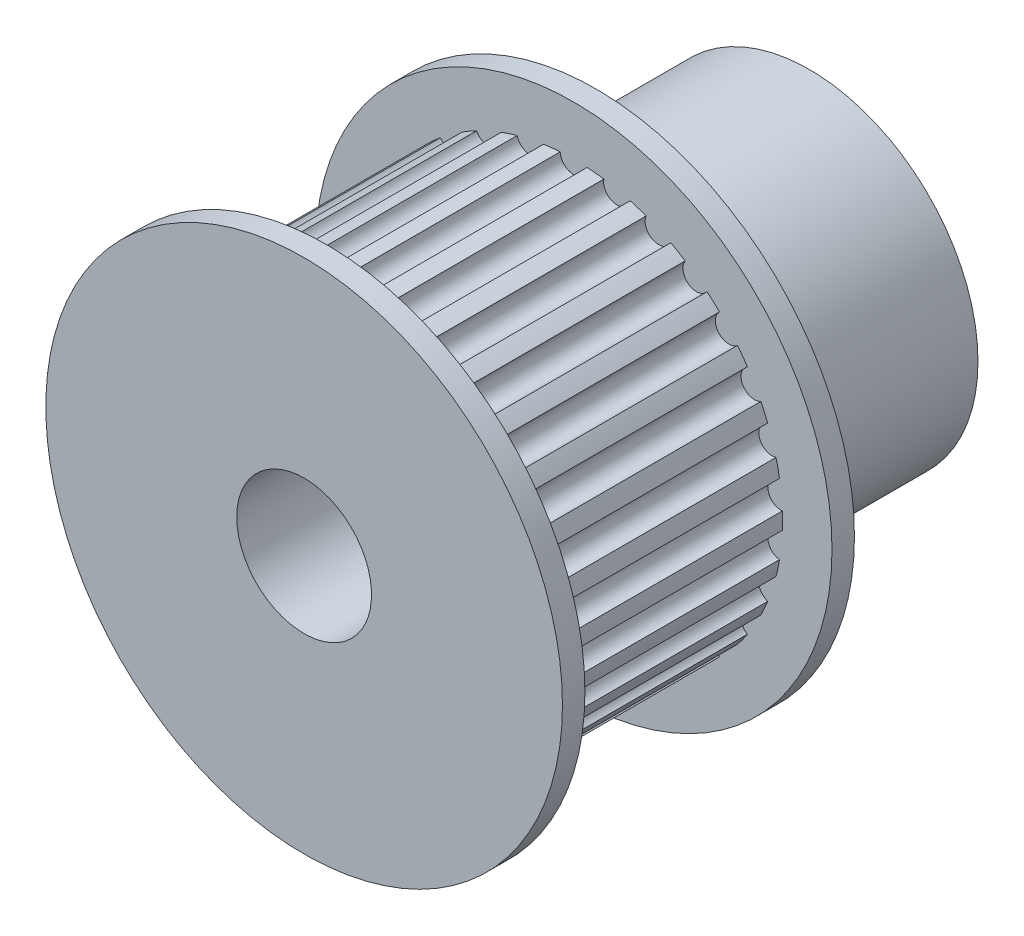
from build123d import *

# Parameters (mm, degrees)
SKETCH_1_R               = 11.5
EXTRUDE_1_DEPTH          = 0.5
SKETCH_2_R               = 9.295
EXTRUDE_2_DEPTH          = 11
SKETCH_8_R               = 7.5
EXTRUDE_4_DEPTH          = 10
CUT_EXTRUDE_3_DEPTH      = 11
SKETCH_3_R               = 11.5
EXTRUDE_3_DEPTH          = 1
SKETCH_6_R               = 3
CUT_EXTRUDE_2_DEPTH      = 10.5
CUT_EXTRUDE_2_DEPTH_BACK = 14
PATTERN_CIRCULAR_2_COUNT = 30


with BuildPart() as part:
    # 草圖1 → 填料-伸長1 (new body, symmetric)
    with BuildSketch(Plane.XY):
        Circle(SKETCH_1_R)
    extrude(amount=EXTRUDE_1_DEPTH, both=True)

    # 草圖2 → 填料-伸長2 (add)
    with BuildSketch(Plane.XY.offset(0.5)):
        Circle(SKETCH_2_R)
    extrude(amount=EXTRUDE_2_DEPTH)

    # 草圖8 → 填料-伸長4 (add)
    with BuildSketch(Plane(origin=(0, 0, 0), x_dir=(-1, 0, 0), z_dir=(0, 0, -1))):
        Circle(SKETCH_8_R)
    extrude(amount=EXTRUDE_4_DEPTH)

    # 草圖7 → 除料-伸長3 (cut)
    with BuildSketch(Plane.XY.offset(11.5)):
        with BuildLine():
            ThreePointArc((-0.599687408, 9.27563475), (0, 8.695), (0.599687408, 9.27563475))
            ThreePointArc((0.599687408, 9.27563475), (0, 9.295), (-0.599687408, 9.27563475))
        make_face()
    cut_extrude_3 = extrude(amount=-CUT_EXTRUDE_3_DEPTH, mode=Mode.SUBTRACT)

    # 草圖3 → 填料-伸長3 (add)
    with BuildSketch(Plane.XY.offset(11.5)):
        Circle(SKETCH_3_R)
    extrude(amount=EXTRUDE_3_DEPTH)

    # 草圖6 → 除料-伸長2 (cut, two sides)
    with BuildSketch(Plane(origin=(0, 0, -0.5), x_dir=(-1, 0, 0), z_dir=(0, 0, -1))) as cut_extrude_2_sk:
        Circle(SKETCH_6_R)
    extrude(amount=CUT_EXTRUDE_2_DEPTH, mode=Mode.SUBTRACT)
    extrude(cut_extrude_2_sk.sketch, amount=-CUT_EXTRUDE_2_DEPTH_BACK, mode=Mode.SUBTRACT)

    # 環狀複製排列2: 除料-伸長3 ×30 about axis
    pattern_circular_2_axis = Axis((0, 0, 0), (0, 0, 1))
    for i in range(1, PATTERN_CIRCULAR_2_COUNT):
        add(cut_extrude_3.rotate(pattern_circular_2_axis, i * 360 / PATTERN_CIRCULAR_2_COUNT), mode=Mode.SUBTRACT)


solid = part.part
